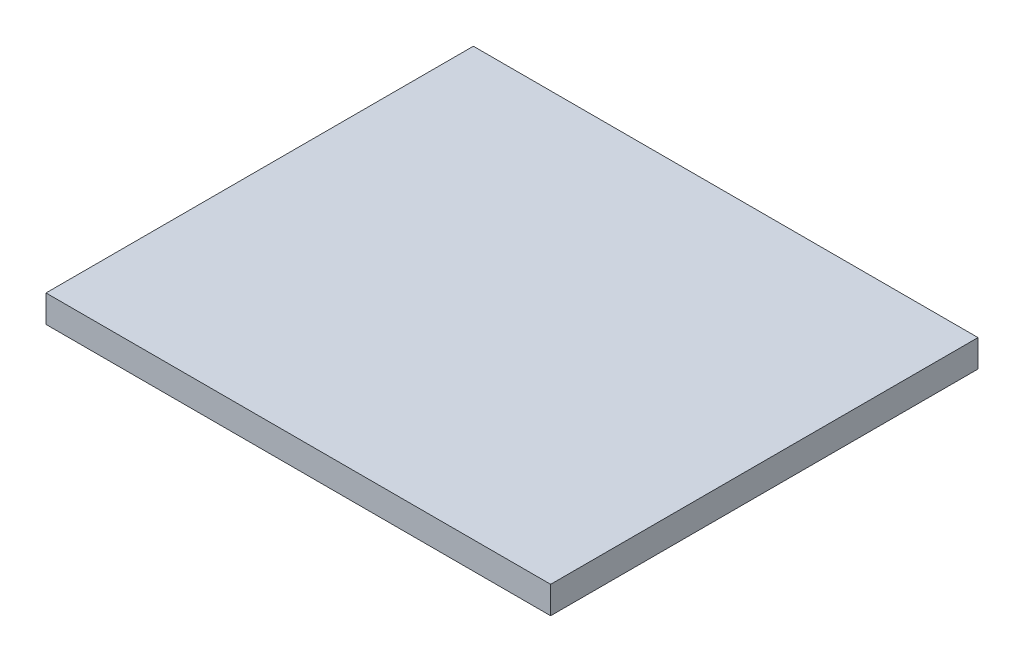
from build123d import *

# Parameters (mm, degrees)
SKETCH1_W           = 111
SKETCH1_H           = 94
BOSS_EXTRUDE1_DEPTH = 6


with BuildPart() as part:
    # Sketch1 → Boss-Extrude1 (new body)
    with BuildSketch(Plane(origin=(0, 0, 0), x_dir=(1, 0, 0), z_dir=(0, 1, 0))):
        with Locations((55.5, 47)):
            Rectangle(SKETCH1_W, SKETCH1_H)
    extrude(amount=BOSS_EXTRUDE1_DEPTH)


solid = part.part
